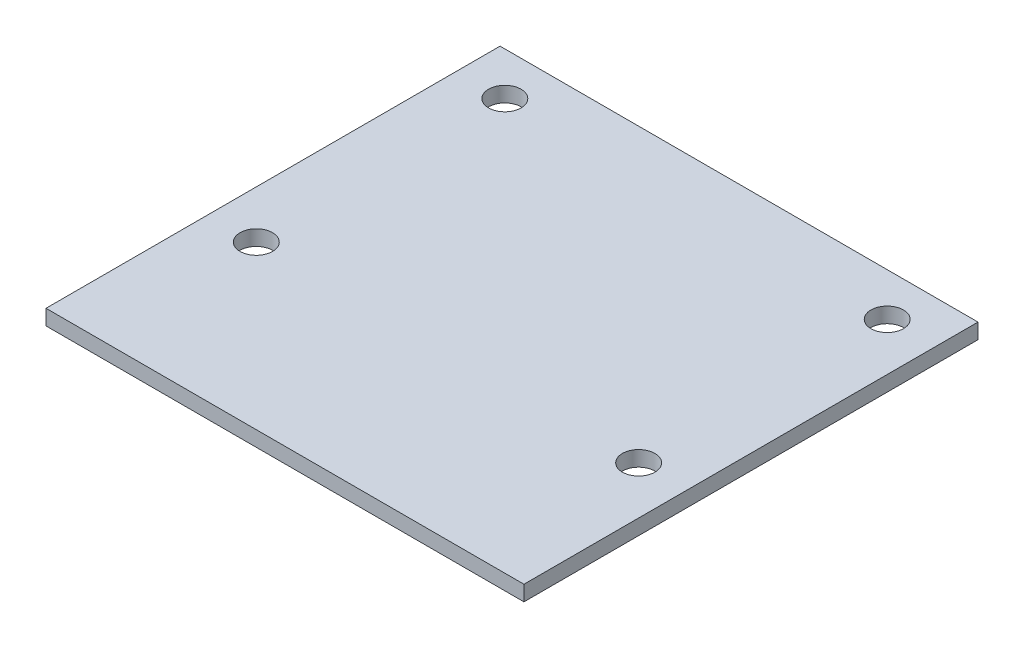
from build123d import *

# Parameters (mm, degrees)
SKETCH1_W           = 50
SKETCH1_H           = 47.5
SKETCH1_R           = 1.7
BOSS_EXTRUDE1_DEPTH = 1.6


with BuildPart() as part:
    # Sketch1 → Boss-Extrude1 (new body)
    with BuildSketch(Plane(origin=(0, 0, 0), x_dir=(1, 0, 0), z_dir=(0, 1, 0))):
        with Locations((25, 23.75)):
            Rectangle(SKETCH1_W, SKETCH1_H)
        with Locations((5, 17)):
            Circle(SKETCH1_R, mode=Mode.SUBTRACT)
        with Locations((5, 43)):
            Circle(SKETCH1_R, mode=Mode.SUBTRACT)
        with Locations((45, 17)):
            Circle(SKETCH1_R, mode=Mode.SUBTRACT)
        with Locations((45, 43)):
            Circle(SKETCH1_R, mode=Mode.SUBTRACT)
    extrude(amount=BOSS_EXTRUDE1_DEPTH)


solid = part.part
